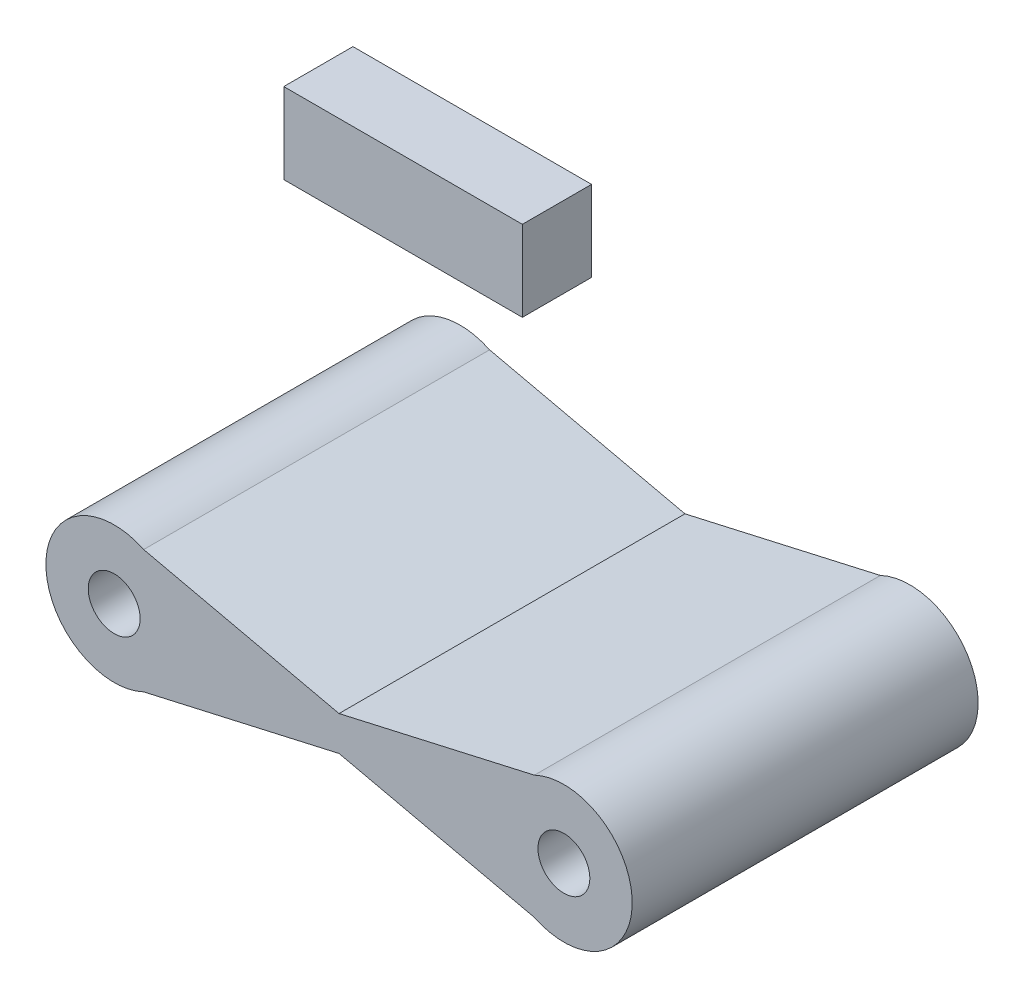
from build123d import *

# Parameters (mm, degrees)
SKETCH1_R           = 0.75
BOSS_EXTRUDE1_DEPTH = 10
SKETCH3_W           = 6.897403567
SKETCH3_H           = 2.329912157
BOSS_EXTRUDE3_DEPTH = 2


with BuildPart() as part:
    # Sketch1 → Boss-Extrude1 (new body)
    with BuildSketch(Plane.XY):
        with BuildLine():
            Line((12.147549978, 2.281559418), (6.5, 1))
            Line((6.5, 1), (0.852450022, 2.281559418))
            ThreePointArc((0.852450022, 2.281559418), (-1.975, 0.5), (0.852450022, -1.281559418))
            Line((0.852450022, -1.281559418), (6.5, 0))
            Line((6.5, 0), (12.147549978, -1.281559418))
            ThreePointArc((12.147549978, -1.281559418), (14.975, 0.5), (12.147549978, 2.281559418))
        make_face()
        with Locations((0, 0.5)):
            Circle(SKETCH1_R, mode=Mode.SUBTRACT)
        with Locations((13, 0.5)):
            Circle(SKETCH1_R, mode=Mode.SUBTRACT)
    extrude(amount=BOSS_EXTRUDE1_DEPTH)


with BuildPart() as body_2:
    # Sketch3 → Boss-Extrude3 (new body)
    with BuildSketch(Plane(origin=(0, 0, 0), x_dir=(-1, 0, 0), z_dir=(0, 0, -1))):
        with Locations((-0.350841319, 6.733030307)):
            Rectangle(SKETCH3_W, SKETCH3_H)
    extrude(amount=-BOSS_EXTRUDE3_DEPTH)


solid = Compound([part.part, body_2.part])
